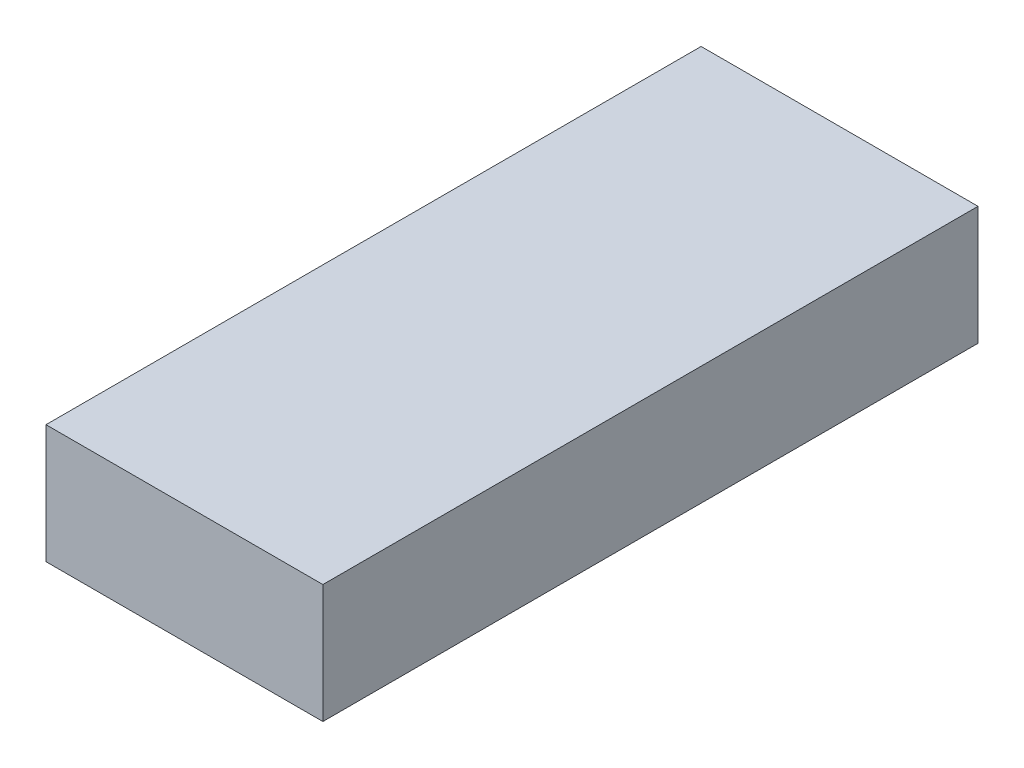
from build123d import *

# Parameters (mm, degrees)
SKETCH1_W           = 88.9
SKETCH1_H           = 38.1
BOSS_EXTRUDE1_DEPTH = 210.34375


with BuildPart() as part:
    # Sketch1 → Boss-Extrude1 (new body)
    with BuildSketch(Plane.XY):
        with Locations((35.456796519, 22.446208883)):
            Rectangle(SKETCH1_W, SKETCH1_H)
    extrude(amount=BOSS_EXTRUDE1_DEPTH)


solid = part.part
